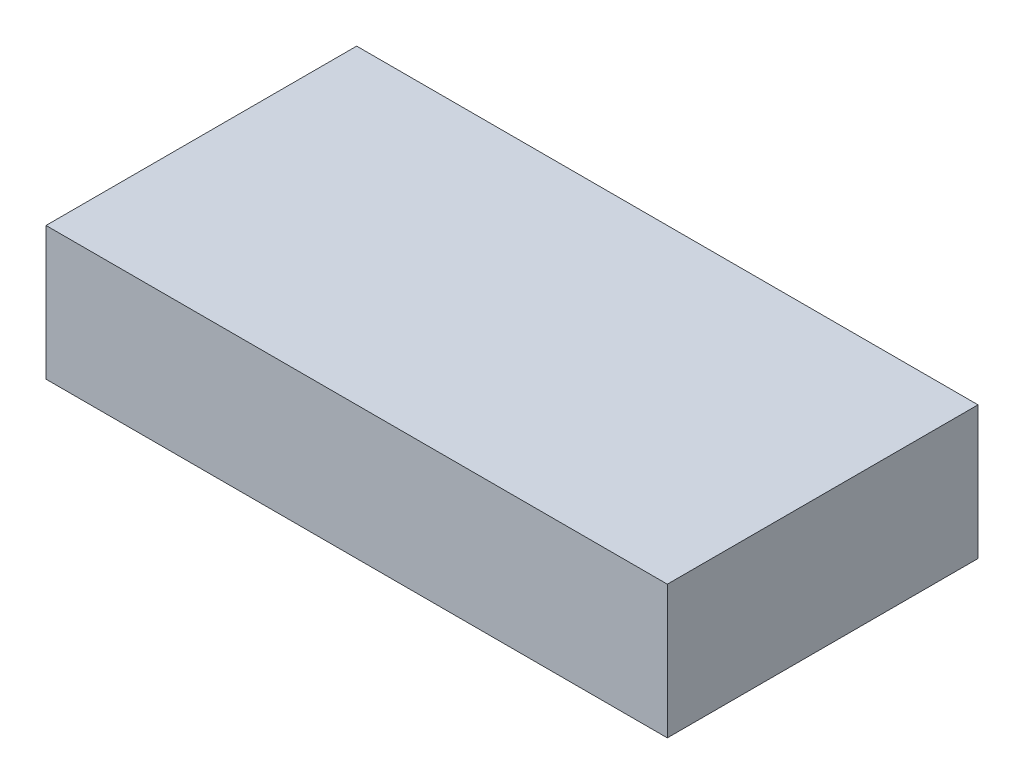
from build123d import *

# Parameters (mm, degrees)
SKETCH1_W           = 70
SKETCH1_H           = 35
BOSS_EXTRUDE1_DEPTH = 15


with BuildPart() as part:
    # Sketch1 → Boss-Extrude1 (new body)
    with BuildSketch(Plane(origin=(0, 0, 0), x_dir=(1, 0, 0), z_dir=(0, 1, 0))):
        Rectangle(SKETCH1_W, SKETCH1_H)
    extrude(amount=BOSS_EXTRUDE1_DEPTH)


solid = part.part
